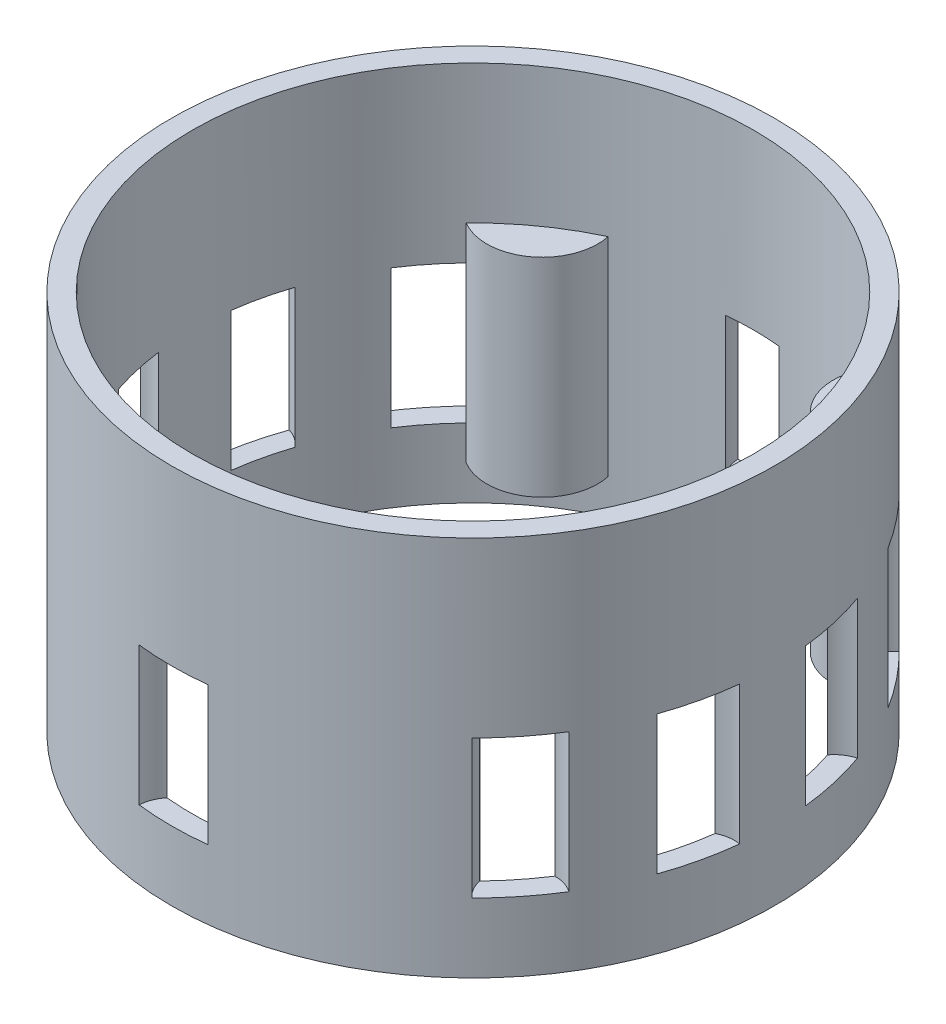
from build123d import *

# Parameters (mm, degrees)
SKETCH1_R               = 43.5
SKETCH1_R_2             = 40.5
BOSS_EXTRUDE1_DEPTH     = 30
SKETCH2_R               = 43.5
SKETCH2_R_2             = 40.5
BOSS_EXTRUDE2_DEPTH     = 20
BOSS_EXTRUDE3_START     = 5
SKETCH3_R               = 43.5
SKETCH3_R_2             = 40.5
BOSS_EXTRUDE3_DEPTH     = 5
CUT_EXTRUDE1_DEPTH      = 10
CUT_EXTRUDE1_DEPTH_BACK = 10


with BuildPart() as part:
    # Sketch1 → Boss-Extrude1 (new body)
    # profile 1 of 5: a face of its own
    with BuildSketch(Plane(origin=(0, 0, 0), x_dir=(1, 0, 0), z_dir=(0, 1, 0))):
        with Locations(Location((0, 0, 0), (0, 0, 270))):
            Circle(SKETCH1_R)
        Circle(SKETCH1_R_2, mode=Mode.SUBTRACT)
    # profile 2 of 5: a face of its own
    with BuildSketch(Plane(origin=(0, 0, 0), x_dir=(1, 0, 0), z_dir=(0, 1, 0))):
        with BuildLine():
            ThreePointArc((-29.123002918, 28.14428363), (-20.35009445, 28.49013223), (-17.177672758, 36.676662316))
            ThreePointArc((-17.177672758, 36.676662316), (-23.540146846, 32.956205584), (-29.123002918, 28.14428363))
        make_face()
    # profile 3 of 5: a face of its own
    with BuildSketch(Plane(origin=(0, 0, 0), x_dir=(1, 0, 0), z_dir=(0, 1, 0))):
        with BuildLine():
            ThreePointArc((-29.123002918, -28.14428363), (-23.540146846, -32.956205584), (-17.177672758, -36.676662316))
            ThreePointArc((-17.177672758, -36.676662316), (-20.35009445, -28.49013223), (-29.123002918, -28.14428363))
        make_face()
    # profile 4 of 5: a face of its own
    with BuildSketch(Plane(origin=(0, 0, 0), x_dir=(1, 0, 0), z_dir=(0, 1, 0))):
        with BuildLine():
            ThreePointArc((17.177672758, -36.676662316), (23.540146846, -32.956205584), (29.123002918, -28.14428363))
            ThreePointArc((29.123002918, -28.14428363), (20.35009445, -28.49013223), (17.177672758, -36.676662316))
        make_face()
    # profile 5 of 5: a face of its own
    with BuildSketch(Plane(origin=(0, 0, 0), x_dir=(1, 0, 0), z_dir=(0, 1, 0))):
        with BuildLine():
            ThreePointArc((17.177672758, 36.676662316), (20.35009445, 28.49013223), (29.123002918, 28.14428363))
            ThreePointArc((29.123002918, 28.14428363), (23.540146846, 32.956205584), (17.177672758, 36.676662316))
        make_face()
    extrude(amount=BOSS_EXTRUDE1_DEPTH)

    # Sketch2 → Boss-Extrude2 (add)
    with BuildSketch(Plane(origin=(0, 30, 0), x_dir=(1, 0, 0), z_dir=(0, 1, 0))):
        with Locations(Location((0, 0, 0), (0, 0, 270))):
            Circle(SKETCH2_R)
        with Locations(Location((0, 0, 0), (0, 0, 64.90375534))):
            Circle(SKETCH2_R_2, mode=Mode.SUBTRACT)
    extrude(amount=BOSS_EXTRUDE2_DEPTH)

    # Sketch3 → Boss-Extrude3 (add)
    with BuildSketch(Plane.XZ.offset(BOSS_EXTRUDE3_START)):
        with Locations(Location((0, 0, 0), (0, 0, 270))):
            Circle(SKETCH3_R)
        with Locations(Location((0, 0, 0), (0, 0, 270))):
            Circle(SKETCH3_R_2, mode=Mode.SUBTRACT)
    extrude(amount=-BOSS_EXTRUDE3_DEPTH)

    # Sketch5 → Cut-Extrude1 (cut, two sides: drawn at the far end of the back side and taken through both)
    with BuildSketch(Plane(origin=(0, 15, 0), x_dir=(1, 0, 0), z_dir=(0, 1, 0)).offset(-CUT_EXTRUDE1_DEPTH_BACK)):
        with BuildLine():
            ThreePointArc((-4.991735805, 43.212643678), (-4.654531608, 41.673709906), (-3.855221077, 40.316091954))
            ThreePointArc((-3.855221077, 40.316091954), (0, 40.5), (3.855221077, 40.316091954))
            ThreePointArc((3.855221077, 40.316091954), (4.654531608, 41.673709906), (4.991735805, 43.212643678))
            ThreePointArc((4.991735805, 43.212643678), (0, 43.5), (-4.991735805, 43.212643678))
        make_face()
        with BuildLine():
            ThreePointArc((33.924080965, 22.122538974), (31.66417504, 25.251336975), (29.116698914, 28.150805394))
            ThreePointArc((29.116698914, 28.150805394), (29.679765405, 29.622192479), (30.6727089, 30.845338849))
            ThreePointArc((30.6727089, 30.845338849), (34.009669487, 27.121806381), (36.897301636, 23.03994644))
            ThreePointArc((36.897301636, 23.03994644), (35.483871385, 22.344073784), (33.924080965, 22.122538974))
        make_face()
        with BuildLine():
            ThreePointArc((40.163150751, 5.212611799), (39.484580443, 9.012097825), (38.447415961, 12.729737071))
            ThreePointArc((38.447415961, 12.729737071), (39.59313227, 13.811105632), (41.018446768, 14.482300396))
            ThreePointArc((41.018446768, 14.482300396), (42.40936418, 9.679660627), (43.239978194, 4.749135264))
            ThreePointArc((43.239978194, 4.749135264), (41.664593712, 4.735440067), (40.163150751, 5.212611799))
        make_face()
        with BuildLine():
            ThreePointArc((41.018446768, -14.482300396), (42.40936418, -9.679660627), (43.239978194, -4.749135264))
            ThreePointArc((43.239978194, -4.749135264), (41.664593712, -4.735440067), (40.163150751, -5.212611799))
            ThreePointArc((40.163150751, -5.212611799), (39.484580443, -9.012097825), (38.447415961, -12.729737071))
            ThreePointArc((38.447415961, -12.729737071), (39.59313227, -13.811105632), (41.018446768, -14.482300396))
        make_face()
        with BuildLine():
            ThreePointArc((29.116698914, -28.150805394), (29.679765405, -29.622192479), (30.6727089, -30.845338849))
            ThreePointArc((30.6727089, -30.845338849), (34.009669487, -27.121806381), (36.897301636, -23.03994644))
            ThreePointArc((36.897301636, -23.03994644), (35.483871385, -22.344073784), (33.924080965, -22.122538974))
            ThreePointArc((33.924080965, -22.122538974), (31.66417504, -25.251336975), (29.116698914, -28.150805394))
        make_face()
        with BuildLine():
            ThreePointArc((4.991735805, -43.212643678), (4.654531608, -41.673709906), (3.855221077, -40.316091954))
            ThreePointArc((3.855221077, -40.316091954), (0, -40.5), (-3.855221077, -40.316091954))
            ThreePointArc((-3.855221077, -40.316091954), (-4.654531608, -41.673709906), (-4.991735805, -43.212643678))
            ThreePointArc((-4.991735805, -43.212643678), (0, -43.5), (4.991735805, -43.212643678))
        make_face()
        with BuildLine():
            ThreePointArc((-36.897301636, -23.03994644), (-34.009669487, -27.121806381), (-30.6727089, -30.845338849))
            ThreePointArc((-30.6727089, -30.845338849), (-29.679765405, -29.622192479), (-29.116698914, -28.150805394))
            ThreePointArc((-29.116698914, -28.150805394), (-31.66417504, -25.251336975), (-33.924080965, -22.122538974))
            ThreePointArc((-33.924080965, -22.122538974), (-35.483871385, -22.344073784), (-36.897301636, -23.03994644))
        make_face()
        with BuildLine():
            ThreePointArc((-43.239978194, -4.749135264), (-42.40936418, -9.679660627), (-41.018446768, -14.482300396))
            ThreePointArc((-41.018446768, -14.482300396), (-39.59313227, -13.811105632), (-38.447415961, -12.729737071))
            ThreePointArc((-38.447415961, -12.729737071), (-39.484580443, -9.012097825), (-40.163150751, -5.212611799))
            ThreePointArc((-40.163150751, -5.212611799), (-41.664593712, -4.735440067), (-43.239978194, -4.749135264))
        make_face()
        with BuildLine():
            ThreePointArc((-38.447415961, 12.729737071), (-39.484580443, 9.012097825), (-40.163150751, 5.212611799))
            ThreePointArc((-40.163150751, 5.212611799), (-41.664593712, 4.735440067), (-43.239978194, 4.749135264))
            ThreePointArc((-43.239978194, 4.749135264), (-42.40936418, 9.679660627), (-41.018446768, 14.482300396))
            ThreePointArc((-41.018446768, 14.482300396), (-39.59313227, 13.811105632), (-38.447415961, 12.729737071))
        make_face()
        with BuildLine():
            ThreePointArc((-29.116698914, 28.150805394), (-29.679765405, 29.622192479), (-30.6727089, 30.845338849))
            ThreePointArc((-30.6727089, 30.845338849), (-34.009669487, 27.121806381), (-36.897301636, 23.03994644))
            ThreePointArc((-36.897301636, 23.03994644), (-35.483871385, 22.344073784), (-33.924080965, 22.122538974))
            ThreePointArc((-33.924080965, 22.122538974), (-31.66417504, 25.251336975), (-29.116698914, 28.150805394))
        make_face()
    extrude(amount=CUT_EXTRUDE1_DEPTH + CUT_EXTRUDE1_DEPTH_BACK, mode=Mode.SUBTRACT)


solid = part.part
